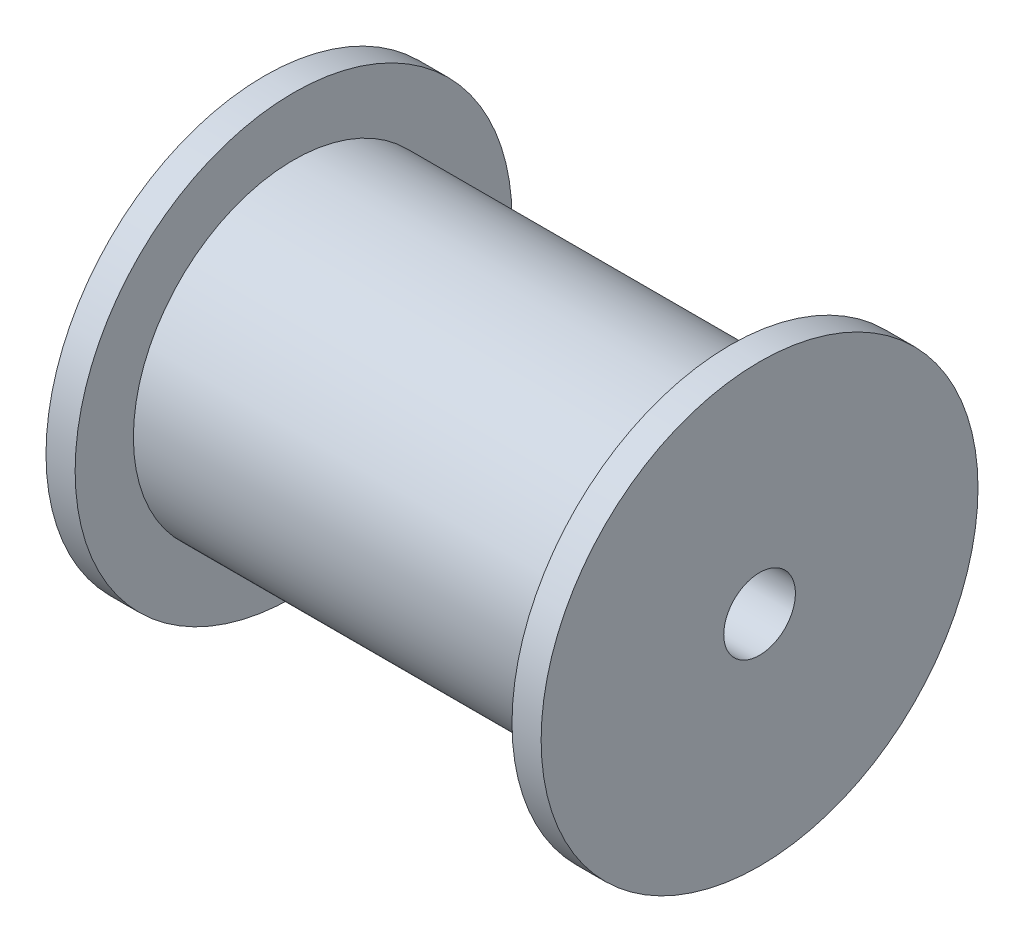
from build123d import *

# Parameters (mm, degrees)
SKETCH2_R          = 3.1242
CUT_EXTRUDE1_DEPTH = 51.8


with BuildPart() as part:
    # Sketch1 → Revolve1 (revolve)
    with BuildSketch(Plane.XY):
        Polygon((-25.4, 0), (25.4, 0), (25.4, 19.05), (22.86, 19.05), (22.86, 13.97), (-15.24, 13.97), (-15.24, 19.05), (-17.78, 19.05), (-17.78, 6.35), (-25.4, 6.35), align=None)
    revolve(axis=Axis((-25.4, 0, 0), (1, 0, 0)))

    # Sketch2 → Cut-Extrude1 (cut, through all)
    with BuildSketch(Plane.ZY.offset(25.4)):
        Circle(SKETCH2_R)
    extrude(amount=-CUT_EXTRUDE1_DEPTH, mode=Mode.SUBTRACT)


solid = part.part
